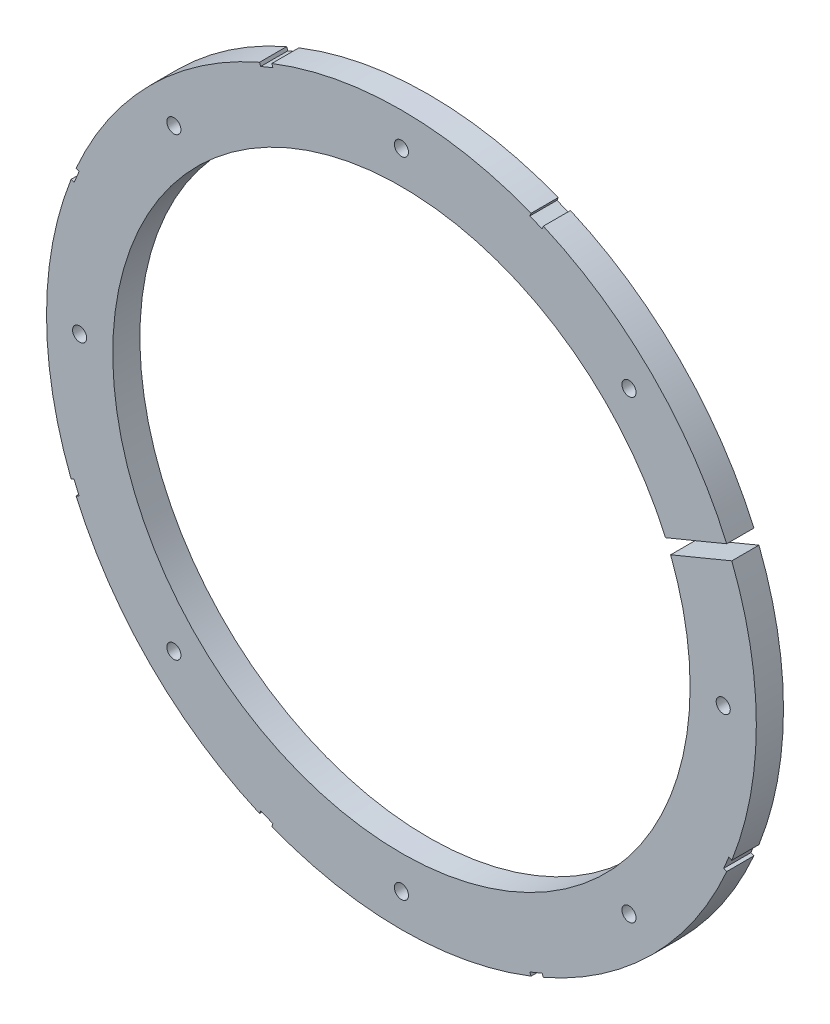
from build123d import *

# Parameters (mm, degrees)
SKETCH4_R             = 68.072
BOSS_EXTRUDE2_DEPTH   = 5.207
SKETCH5_R             = 55.372
CUT_EXTRUDE5_DEPTH    = 6.207
CUT_EXTRUDE11_DEPTH   = 6.207
F_6_32_TAPPED_HOLE1_D = 2.7051


with BuildPart() as part:
    # Sketch4 → Boss-Extrude2 (new body)
    with BuildSketch(Plane.XY):
        Circle(SKETCH4_R)
    extrude(amount=BOSS_EXTRUDE2_DEPTH)

    # Sketch5 → Cut-Extrude5 (cut, through all)
    with BuildSketch(Plane.XY.offset(5.207)):
        Circle(SKETCH5_R)
    extrude(amount=-CUT_EXTRUDE5_DEPTH, mode=Mode.SUBTRACT)

    # Sketch8 → Cut-Extrude11 (cut, through all)
    with BuildSketch(Plane.XY.offset(5.207)):
        Polygon((68.857618113, 29.896397389), (50.084386012, 22.120270044), (51.05640193, 19.773616031), (69.829634031, 27.549743377), align=None)
        Polygon((27.466357594, 62.990983081), (25.119703581, 63.962998999), (24.633695622, 62.789671993), (26.980349635, 61.817656075), align=None)
        Polygon((-25.119703581, 63.962998999), (-27.466357594, 62.990983081), (-26.980349635, 61.817656075), (-24.633695622, 62.789671993), align=None)
        Polygon((-62.990983081, 27.466357594), (-63.962998999, 25.119703581), (-62.789671993, 24.633695622), (-61.817656075, 26.980349635), align=None)
        Polygon((-63.962998999, -25.119703581), (-62.990983081, -27.466357594), (-61.817656075, -26.980349635), (-62.789671993, -24.633695622), align=None)
        Polygon((-27.466357594, -62.990983081), (-25.119703581, -63.962998999), (-24.633695622, -62.789671993), (-26.980349635, -61.817656075), align=None)
        Polygon((25.119703581, -63.962998999), (27.466357594, -62.990983081), (26.980349635, -61.817656075), (24.633695622, -62.789671993), align=None)
        Polygon((62.990983081, -27.466357594), (63.962998999, -25.119703581), (62.789671993, -24.633695622), (61.817656075, -26.980349635), align=None)
    extrude(amount=-CUT_EXTRUDE11_DEPTH, mode=Mode.SUBTRACT)

    # #6-32 Tapped Hole1 (through all)
    with Locations(Plane.XY.offset(5.207)):
        with Locations((61.722, 0), (43.644044748, -43.644044748), (0, -61.722), (-43.644044748, -43.644044748), (-61.722, 0), (-43.644044748, 43.644044748), (0, 61.722), (43.644044748, 43.644044748)):
            Hole(F_6_32_TAPPED_HOLE1_D / 2)


solid = part.part
